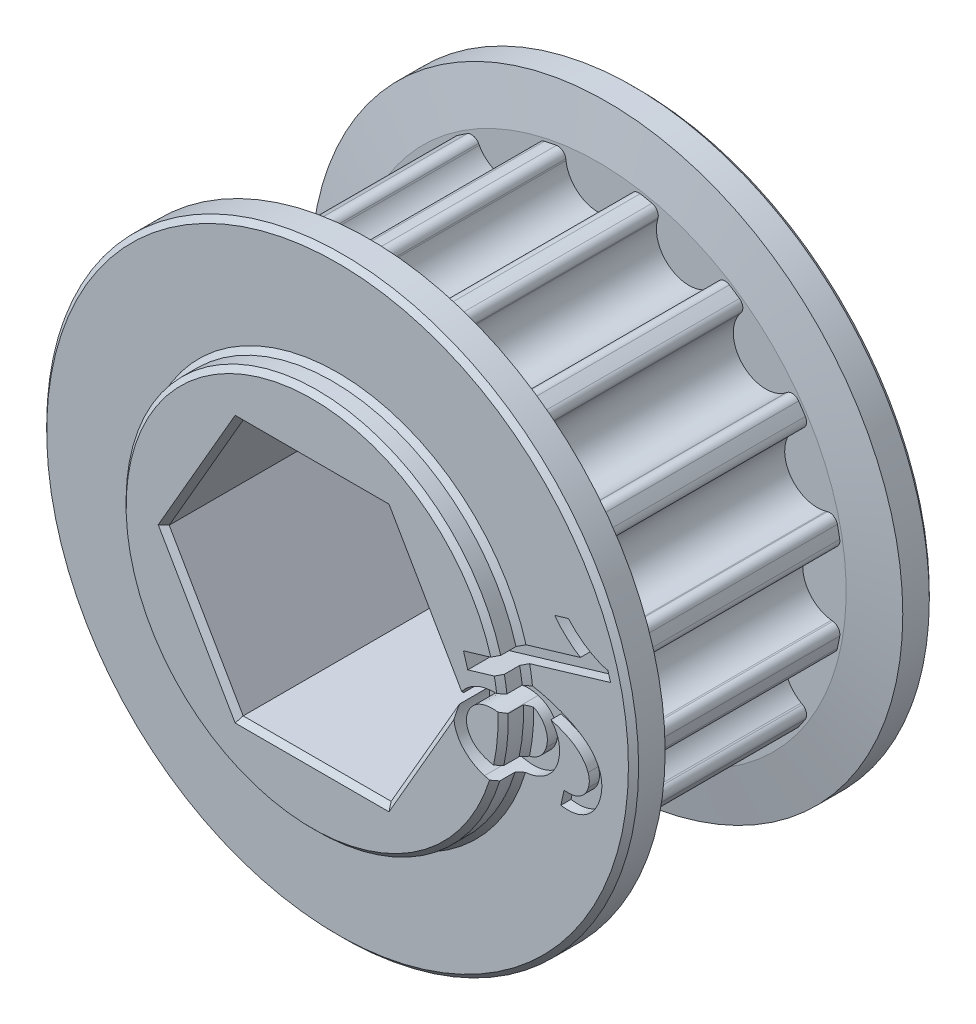
from build123d import *

# Parameters (mm, degrees)
SKETCH2_R                                 = 12.214576928
PULLEY_DEPTH                              = 5.500000049
CUT_TOOTH_DEPTH                           = 5.500000049
BLEND_TOOTH_R                             = 0.4
TOOTH_PATTERN_COUNT                       = 16
BLEND_TOOTH_OF_TOOTH_PATTERN_R            = 0.4
SIDEWALL_START                            = 5.500000049
SKETCH3_R                                 = 14.754576928
SIDEWALL_DEPTH                            = 2.000000064
SIDEWALL_CHAMFER_SIZE                     = 2.400000026
SIDEWALL_CHAMFER_SIZE2                    = 0.423184758
SIDEWALL_CHAMFER_PART_2_SIZE              = 2.400000026
SIDEWALL_CHAMFER_PART_2_SIZE2             = 0.423184758
SKETCH5_R                                 = 9.525
BEARING_SPACER_MANUAL_SUPPRESS_DEPTH      = 8.770000113
BEARING_SPACER_MANUAL_SUPPRESS_DEPTH_BACK = 8.770000113
HEX_SHAFT_DEPTH                           = 63.5
CHAMFERS_SIZE                             = 0.254
CUT_EXTRUDE_START                         = 6.992000113
CUT_EXTRUDE_4419_DEPTH                    = 2.54


with BuildPart() as part:
    # Sketch2 → pulley (new body, symmetric)
    with BuildSketch(Plane.XY):
        Circle(SKETCH2_R)
    extrude(amount=PULLEY_DEPTH, both=True)

    # tooth → cut tooth (cut, symmetric)
    with BuildSketch(Plane.XY):
        with BuildLine():
            Line((-2.132711961, 15.850169375), (-1.612887548, 11.616539276))
            ThreePointArc((-1.612887548, 11.616539276), (0, 10.189576914), (1.612887548, 11.616539276))
            Line((1.612887548, 11.616539276), (2.132711961, 15.850169375))
            Line((2.132711961, 15.850169375), (-2.132711961, 15.850169375))
        make_face()
    cut_tooth = extrude(amount=CUT_TOOTH_DEPTH, both=True, mode=Mode.SUBTRACT)

    # blend tooth
    blend_tooth_edges = [part.edges().sort_by_distance(p)[0] for p in [
        (1.672196538, 12.099572235, 0),
        (-1.672196538, 12.099572235, 0),
    ]]
    fillet(blend_tooth_edges, radius=BLEND_TOOTH_R)

    # tooth pattern: cut tooth ×16 about axis
    tooth_pattern_axis = Axis((0, 0, 0), (0, 0, 1))
    for i in range(1, TOOTH_PATTERN_COUNT):
        add(cut_tooth.rotate(tooth_pattern_axis, i * 360 / TOOTH_PATTERN_COUNT), mode=Mode.SUBTRACT)

    # blend tooth of tooth pattern
    blend_tooth_of_tooth_pattern_edges = [part.edges().sort_by_distance(p)[0] for p in [
        (-3.085397677, 11.81846905, 0),
        (-6.175213988, 10.538625229, 0),
        (-7.373268065, 9.738111088, 0),
        (-9.738111088, 7.373268065, 0),
        (-10.538625229, 6.175213988, 0),
        (-11.81846905, 3.085397677, 0),
        (-12.099572235, 1.672196538, 0),
        (-12.099572235, -1.672196538, 0),
        (-11.81846905, -3.085397677, 0),
        (-10.538625229, -6.175213988, 0),
        (-9.738111088, -7.373268065, 0),
        (-7.373268065, -9.738111088, 0),
        (-6.175213988, -10.538625229, 0),
        (-3.085397677, -11.81846905, 0),
        (-1.672196538, -12.099572235, 0),
        (1.672196538, -12.099572235, 0),
        (3.085397677, -11.81846905, 0),
        (6.175213988, -10.538625229, 0),
        (7.373268065, -9.738111088, 0),
        (9.738111088, -7.373268065, 0),
        (10.538625229, -6.175213988, 0),
        (11.81846905, -3.085397677, 0),
        (12.099572235, -1.672196538, 0),
        (12.099572235, 1.672196538, 0),
        (11.81846905, 3.085397677, 0),
        (10.538625229, 6.175213988, 0),
        (9.738111088, 7.373268065, 0),
        (7.373268065, 9.738111088, 0),
        (6.175213988, 10.538625229, 0),
        (3.085397677, 11.81846905, 0),
    ]]
    fillet(blend_tooth_of_tooth_pattern_edges, radius=BLEND_TOOTH_OF_TOOTH_PATTERN_R)

    # Sketch3 → sidewall (add)
    with BuildSketch(Plane.XY.offset(SIDEWALL_START)):
        Circle(SKETCH3_R)
    sidewall = extrude(amount=SIDEWALL_DEPTH)

    # mirror sidewall: sidewall across plane
    add(sidewall.mirror(Plane.XY))

    # sidewall chamfer
    sidewall_chamfer_edges = [part.edges().sort_by_distance(p)[0] for p in [
        (-14.754576928, 0, 5.500000049),
    ]]
    sidewall_chamfer_side = [part.faces().sort_by_distance(p)[0] for p in [
        (-14.337254472, 0, 5.500000049),
    ]]
    chamfer(sidewall_chamfer_edges, length=SIDEWALL_CHAMFER_SIZE, length2=SIDEWALL_CHAMFER_SIZE2, reference=sidewall_chamfer_side[0])

    # sidewall chamfer part 2
    sidewall_chamfer_part_2_edges = [part.edges().sort_by_distance(p)[0] for p in [
        (-14.754576928, 0, -5.500000049),
    ]]
    sidewall_chamfer_part_2_side = [part.faces().sort_by_distance(p)[0] for p in [
        (-14.337254472, 0, -5.500000049),
    ]]
    chamfer(sidewall_chamfer_part_2_edges, length=SIDEWALL_CHAMFER_PART_2_SIZE, length2=SIDEWALL_CHAMFER_PART_2_SIZE2, reference=sidewall_chamfer_part_2_side[0])

    # Sketch5 → bearing spacer (Manual Suppress) (add, two sides)
    with BuildSketch(Plane.XY) as bearing_spacer_manual_suppress_sk:
        Circle(SKETCH5_R)
    extrude(amount=BEARING_SPACER_MANUAL_SUPPRESS_DEPTH)
    extrude(bearing_spacer_manual_suppress_sk.sketch, amount=-BEARING_SPACER_MANUAL_SUPPRESS_DEPTH_BACK)

    # Sketch4 → hex shaft (cut, symmetric)
    with BuildSketch(Plane.XY):
        Polygon((3.688171255, 6.3881), (-3.688171255, 6.3881), (-7.376342509, 0), (-3.688171255, -6.3881), (3.688171255, -6.3881), (7.376342509, 0), align=None)
    extrude(amount=HEX_SHAFT_DEPTH, both=True, mode=Mode.SUBTRACT)

    # chamfers
    chamfers_edges = [part.edges().sort_by_distance(p)[0] for p in [
        (-14.754576928, 0, 7.500000113),
        (-14.754576928, 0, -7.500000113),
        (-9.525, 0, -7.500000113),
        (-9.525, 0, 7.500000113),
        (-9.525, 0, -8.770000113),
        (-9.525, 0, 8.770000113),
        (0, 6.3881, 8.770000113),
        (-5.532256882, 3.19405, 8.770000113),
        (-5.532256882, -3.19405, 8.770000113),
        (0, -6.3881, 8.770000113),
        (5.532256882, -3.19405, 8.770000113),
        (5.532256882, 3.19405, 8.770000113),
        (5.532256882, 3.19405, -8.770000113),
        (5.532256882, -3.19405, -8.770000113),
        (0, -6.3881, -8.770000113),
        (-5.532256882, -3.19405, -8.770000113),
        (-5.532256882, 3.19405, -8.770000113),
        (0, 6.3881, -8.770000113),
    ]]
    chamfer(chamfers_edges, length=CHAMFERS_SIZE)

    # Sketch6 → 4419 (cut)
    with BuildSketch(Plane.XY.offset(CUT_EXTRUDE_START)):
        with BuildLine():
            Line((7.76109638, 1.450492503), (7.547481412, 2.165423521))
            Line((7.547481412, 2.165423521), (12.106247078, 3.523668979))
            add(Edge.make_bspline(
                [(12.106247078, 3.523668979), (12.051126015, 3.557656224), (11.936207257, 3.62851429), (11.764496927, 3.751093086), (11.5882852, 3.895384736), (11.409784811, 4.054731813), (11.238167849, 4.221257546), (11.078758508, 4.383627346), (10.940447861, 4.541944731), (10.857091615, 4.647400995), (10.817148661, 4.697933917)],
                knots=[0, 0, 0, 0, 0.000194236, 0.000404951, 0.000632313, 0.000877183, 0.001122567, 0.001349603, 0.001559616, 0.00175284, 0.00175284, 0.00175284, 0.00175284], degree=3))
            Line((10.817148661, 4.697933917), (11.509853845, 4.904140273))
            add(Edge.make_bspline(
                [(11.509853845, 4.904140273), (11.586764916, 4.820535644), (11.738280512, 4.655833669), (11.98489902, 4.434129205), (12.237854463, 4.232458593), (12.498340593, 4.058240436), (12.756784935, 3.910539639), (13.005885876, 3.792820784), (13.242526815, 3.703790766), (13.399379474, 3.670480215), (13.474370685, 3.654554451)],
                knots=[0, 0, 0, 0, 0.000340626, 0.000671037, 0.000993661, 0.001310441, 0.001610165, 0.001885795, 0.002136553, 0.002366267, 0.002366267, 0.002366267, 0.002366267], degree=3))
            Line((13.474370685, 3.654554451), (13.611429999, 3.193985764))
            Line((13.611429999, 3.193985764), (7.76109638, 1.450492503))
        make_face()
        with BuildLine():
            Line((11.133700715, -3.344707701), (11.289281559, -2.616194227))
            add(Edge.make_bspline(
                [(11.289281559, -2.616194227), (11.360076462, -2.619669946), (11.492722026, -2.626182259), (11.67988964, -2.614300813), (11.842446362, -2.584816969), (11.937572923, -2.546442422), (11.981986743, -2.528525657)],
                knots=[0, 0, 0, 0, 0.00021247, 0.000398096, 0.000561795, 0.000705161, 0.000705161, 0.000705161, 0.000705161], degree=3))
            add(Edge.make_bspline(
                [(11.981986743, -2.528525657), (12.013637727, -2.511443093), (12.076259941, -2.47764484), (12.162267719, -2.417089053), (12.240465143, -2.349576583), (12.308985524, -2.273789311), (12.371460331, -2.192771886), (12.423608892, -2.103248752), (12.468347989, -2.00745877), (12.490579706, -1.939394071), (12.501824323, -1.904967515)],
                knots=[0, 0, 0, 0, 0.000107822, 0.000213327, 0.000314849, 0.000417097, 0.000519337, 0.000621196, 0.000727271, 0.000835832, 0.000835832, 0.000835832, 0.000835832], degree=3))
            add(Edge.make_bspline(
                [(12.501824323, -1.904967515), (12.516644347, -1.848920167), (12.545732939, -1.738911011), (12.553540122, -1.570149503), (12.53997991, -1.404293204), (12.506365305, -1.299490755), (12.489476637, -1.246835852)],
                knots=[0, 0, 0, 0, 0.00017344, 0.000340426, 0.000504204, 0.000669576, 0.000669576, 0.000669576, 0.000669576], degree=3))
            add(Edge.make_bspline(
                [(12.489476637, -1.246835852), (12.461375357, -1.179197108), (12.404187442, -1.041547903), (12.278986352, -0.848081678), (12.118247146, -0.66710003), (11.961745892, -0.523158808), (11.815677712, -0.415209418), (11.690737055, -0.333312993), (11.550933591, -0.254946086), (11.397337299, -0.178073409), (11.228803246, -0.104531847), (11.046152141, -0.031538275), (10.848767122, 0.038618464), (10.711554025, 0.081804078), (10.641028045, 0.104000995)],
                knots=[0, 0, 0, 0, 0.000219403, 0.0004465, 0.000687179, 0.000944165, 0.001082707, 0.001231685, 0.001392038, 0.001563222, 0.001746767, 0.001943498, 0.002153224, 0.002375022, 0.002375022, 0.002375022, 0.002375022], degree=3))
            add(Edge.make_bspline(
                [(10.641028045, 0.104000995), (10.690316331, 0.041299403), (10.78671993, -0.081339455), (10.902680364, -0.280593913), (10.987819385, -0.487553024), (11.041516192, -0.700241006), (11.068410914, -0.914263131), (11.071321826, -1.126811699), (11.048487441, -1.337334302), (11.013149508, -1.473551865), (10.995406632, -1.541945547)],
                knots=[0, 0, 0, 0, 0.000239051, 0.000467564, 0.000689066, 0.000908285, 0.001123621, 0.00133478, 0.001544771, 0.001756526, 0.001756526, 0.001756526, 0.001756526], degree=3))
            add(Edge.make_bspline(
                [(10.995406632, -1.541945547), (10.976450556, -1.600033759), (10.939026759, -1.714713687), (10.862626163, -1.876471221), (10.773671066, -2.027867376), (10.667806062, -2.166180817), (10.548668113, -2.2938851), (10.415974792, -2.411415862), (10.266609523, -2.514251398), (10.106228194, -2.60711188), (9.935015397, -2.682710105), (9.758460396, -2.743058963), (9.576045204, -2.78206718), (9.389251985, -2.805049608), (9.196798056, -2.806902016), (8.999905342, -2.789934483), (8.797440172, -2.75770312), (8.663446852, -2.720429099), (8.595016477, -2.701393261)],
                knots=[0, 0, 0, 0, 0.00018315, 0.000361581, 0.000535438, 0.00070905, 0.000882907, 0.001058769, 0.001239636, 0.001426025, 0.001613958, 0.001800211, 0.001984767, 0.002172537, 0.002363942, 0.002560925, 0.002764935, 0.002977867, 0.002977867, 0.002977867, 0.002977867], degree=3))
            add(Edge.make_bspline(
                [(8.595016477, -2.701393261), (8.50563373, -2.671929034), (8.329258415, -2.613788483), (8.082078256, -2.488434038), (7.851659119, -2.340355191), (7.677077187, -2.193762098), (7.549112271, -2.066563351), (7.462244463, -1.966680422), (7.382333206, -1.864365667), (7.313012893, -1.75709874), (7.249886254, -1.647638305), (7.197088533, -1.533866394), (7.152666792, -1.416612136), (7.104765519, -1.25631016), (7.066353394, -1.049989387), (7.057378797, -0.79655903), (7.080849096, -0.538136652), (7.125226749, -0.368849693), (7.147867679, -0.282481576)],
                knots=[0, 0, 0, 0, 0.000281987, 0.000556434, 0.000828714, 0.00110222, 0.001238425, 0.001369683, 0.001499098, 0.001627526, 0.0017525, 0.001877895, 0.002003338, 0.002128349, 0.002379493, 0.002630345, 0.002887133, 0.003154602, 0.003154602, 0.003154602, 0.003154602], degree=3))
            add(Edge.make_bspline(
                [(7.147867679, -0.282481576), (7.171526368, -0.210321616), (7.217974961, -0.068651519), (7.311409939, 0.13151862), (7.423254112, 0.314676665), (7.550452591, 0.483306729), (7.697272379, 0.632911354), (7.860978283, 0.766461333), (8.041760261, 0.883794838), (8.240536919, 0.98501303), (8.459534793, 1.06445466), (8.699981111, 1.119149344), (8.961929152, 1.143895862), (9.24454475, 1.148302099), (9.547889511, 1.122678502), (9.872428247, 1.073955559), (10.218468233, 0.999780033), (10.453710235, 0.932706774), (10.575585309, 0.897957204)],
                knots=[0, 0, 0, 0, 0.00022767, 0.00044698, 0.000660862, 0.000870533, 0.001079223, 0.001288078, 0.001503159, 0.001724596, 0.001955837, 0.002200262, 0.002462211, 0.002743762, 0.003047189, 0.003374263, 0.003727847, 0.004107967, 0.004107967, 0.004107967, 0.004107967], degree=3))
            add(Edge.make_bspline(
                [(10.575585309, 0.897957204), (10.644402042, 0.876817709), (10.780031328, 0.835154373), (10.978503527, 0.769238761), (11.167857094, 0.697982122), (11.348976935, 0.625992964), (11.521206703, 0.549947084), (11.685147445, 0.473047628), (11.839967609, 0.391903844), (11.987140649, 0.310320937), (12.124309297, 0.222836505), (12.253861672, 0.134772203), (12.374542204, 0.043203037), (12.48493865, -0.052600284), (12.589922545, -0.147855314), (12.683197754, -0.249114175), (12.770613444, -0.350455688), (12.8213541, -0.422408874), (12.846324762, -0.457818717)],
                knots=[0, 0, 0, 0, 0.000215972, 0.000425653, 0.000627257, 0.000822843, 0.001010275, 0.001191992, 0.001365959, 0.001534585, 0.001696622, 0.001853826, 0.002004473, 0.002150724, 0.002292265, 0.002429414, 0.002563481, 0.00269339, 0.00269339, 0.00269339, 0.00269339], degree=3))
            add(Edge.make_bspline(
                [(12.846324762, -0.457818717), (12.885599988, -0.51999459), (12.962965003, -0.64246969), (13.053476669, -0.838086227), (13.119562662, -1.039054556), (13.160260623, -1.246009154), (13.177889697, -1.458527458), (13.169701264, -1.676743616), (13.138093346, -1.900506801), (13.097797248, -2.048150774), (13.07722649, -2.123521557)],
                knots=[0, 0, 0, 0, 0.000220443, 0.000434233, 0.000644699, 0.000853681, 0.001065533, 0.001282979, 0.001507544, 0.001741733, 0.001741733, 0.001741733, 0.001741733], degree=3))
            add(Edge.make_bspline(
                [(13.07722649, -2.123521557), (13.059763766, -2.179474123), (13.025591443, -2.288966159), (12.957447476, -2.443435818), (12.882620275, -2.587706187), (12.797035016, -2.720383686), (12.701752095, -2.842134014), (12.596242462, -2.951998178), (12.482413128, -3.05227638), (12.357331183, -3.137834041), (12.225333032, -3.212394829), (12.086585895, -3.272675659), (11.942559975, -3.320593321), (11.791659333, -3.351807495), (11.635211333, -3.372405202), (11.472812677, -3.375928541), (11.304629922, -3.369769763), (11.191629531, -3.353201366), (11.133700715, -3.344707701)],
                knots=[0, 0, 0, 0, 0.000175711, 0.000343843, 0.000505673, 0.000662882, 0.000816773, 0.000968735, 0.001119276, 0.001271012, 0.001422486, 0.001573436, 0.001724159, 0.001876976, 0.002035031, 0.002196861, 0.00236372, 0.002539235, 0.002539235, 0.002539235, 0.002539235], degree=3))
        make_face()
        with BuildLine():
            add(Edge.make_bspline(
                [(9.492693248, 0.325024574), (9.431239844, 0.341159448), (9.308711246, 0.373329895), (9.119725996, 0.398025805), (8.928843702, 0.399692198), (8.738792263, 0.382959983), (8.554947749, 0.346167328), (8.38371098, 0.285550648), (8.228767149, 0.201652972), (8.09065597, 0.097962356), (7.971362029, -0.02168033), (7.871136331, -0.15250639), (7.791616544, -0.294222958), (7.756759393, -0.39586073), (7.739321838, -0.4467058)],
                knots=[0, 0, 0, 0, 0.000190475, 0.000379777, 0.000569948, 0.000762116, 0.000951245, 0.001130903, 0.001304935, 0.001477803, 0.001647187, 0.001810181, 0.001971009, 0.002132004, 0.002132004, 0.002132004, 0.002132004], degree=3))
            add(Edge.make_bspline(
                [(7.739321838, -0.4467058), (7.729406661, -0.483983439), (7.709770515, -0.557808556), (7.695584596, -0.670981358), (7.692213411, -0.783267837), (7.704713938, -0.894858688), (7.725898844, -1.006187), (7.762917089, -1.116740192), (7.811052631, -1.2267929), (7.871599873, -1.335253525), (7.943502315, -1.439822832), (8.0289354, -1.536571801), (8.123640172, -1.627229464), (8.231050723, -1.708598885), (8.348655276, -1.783650782), (8.47918531, -1.847566296), (8.618913487, -1.908610611), (8.718148663, -1.939650171), (8.769118849, -1.955593027)],
                knots=[0, 0, 0, 0, 0.000115601, 0.000228938, 0.000341329, 0.000451784, 0.000565114, 0.000680695, 0.000800677, 0.000925046, 0.001052807, 0.00118058, 0.001311594, 0.001445451, 0.001584191, 0.001729422, 0.001881017, 0.002041109, 0.002041109, 0.002041109, 0.002041109], degree=3))
            add(Edge.make_bspline(
                [(8.769118849, -1.955593027), (8.818353584, -1.968979695), (8.914490522, -1.995118827), (9.057947607, -2.022899878), (9.197269167, -2.03660394), (9.331100606, -2.037618158), (9.460287594, -2.028591833), (9.583986861, -2.004714919), (9.703192554, -1.968833528), (9.816751135, -1.920947035), (9.922166705, -1.861133594), (10.02106951, -1.795059231), (10.108482163, -1.71783625), (10.18723575, -1.633146445), (10.25666491, -1.539918029), (10.317008859, -1.438574704), (10.368893657, -1.32883426), (10.393727858, -1.250876265), (10.406422011, -1.211027562)],
                knots=[0, 0, 0, 0, 0.000153037, 0.000298823, 0.000437782, 0.000572378, 0.000699942, 0.000825628, 0.000949456, 0.00107284, 0.001194451, 0.001312609, 0.001428998, 0.00154346, 0.001659034, 0.001776985, 0.00189686, 0.002022205, 0.002022205, 0.002022205, 0.002022205], degree=3))
            add(Edge.make_bspline(
                [(10.406422011, -1.211027562), (10.416958381, -1.170848756), (10.437641481, -1.091976975), (10.45705771, -0.972147985), (10.461020818, -0.853750954), (10.455970282, -0.73649079), (10.435045768, -0.621286147), (10.40451008, -0.50693695), (10.360718182, -0.394120501), (10.305484059, -0.283654398), (10.23932848, -0.177884644), (10.162414248, -0.079703389), (10.075021429, 0.009554327), (9.978927007, 0.091491888), (9.871492893, 0.163700474), (9.753710016, 0.225615999), (9.62775863, 0.282677785), (9.53831393, 0.31072121), (9.492693248, 0.325024574)],
                knots=[0, 0, 0, 0, 0.000124583, 0.000244559, 0.0003632, 0.000479432, 0.000595953, 0.000713671, 0.000834059, 0.000958306, 0.001083694, 0.001207694, 0.001331689, 0.001457853, 0.001585936, 0.001719074, 0.001856732, 0.002000035, 0.002000035, 0.002000035, 0.002000035], degree=3))
        make_face(mode=Mode.SUBTRACT)
    extrude(amount=CUT_EXTRUDE_4419_DEPTH, mode=Mode.SUBTRACT)


solid = part.part
